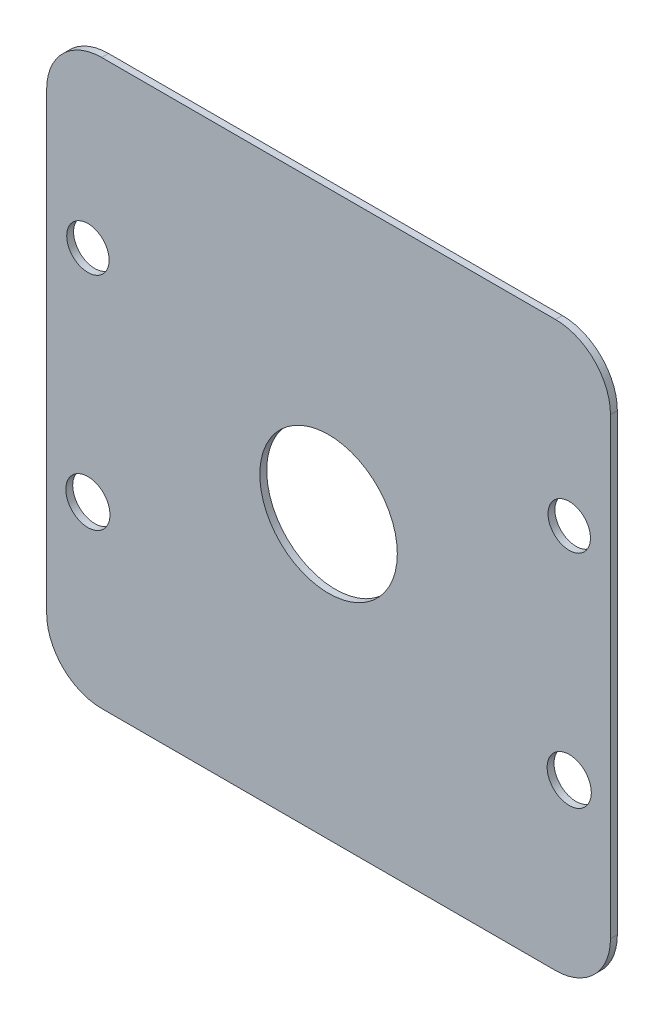
from build123d import *

# Parameters (mm, degrees)
ESBO_O1_R                = 5
ESBO_O1_R_2              = 1.606107272
ESBO_O1_R_3              = 1.541611137
RESSALTO_EXTRUS_O1_DEPTH = 0.5


with BuildPart() as part:
    # Esboço1 → Ressalto-extrusão1 (new body)
    with BuildSketch(Plane.XY):
        with BuildLine():
            Line((-16.5, -20.5), (16.5, -20.5))
            ThreePointArc((16.5, -20.5), (19.328427125, -19.328427125), (20.5, -16.5))
            Line((20.5, -16.5), (20.5, 16.5))
            ThreePointArc((20.5, 16.5), (19.328427125, 19.328427125), (16.5, 20.5))
            Line((16.5, 20.5), (-16.5, 20.5))
            ThreePointArc((-16.5, 20.5), (-19.328427125, 19.328427125), (-20.5, 16.5))
            Line((-20.5, 16.5), (-20.5, -16.5))
            ThreePointArc((-20.5, -16.5), (-19.328427125, -19.328427125), (-16.5, -20.5))
        make_face()
        Circle(ESBO_O1_R, mode=Mode.SUBTRACT)
        with Locations((17.5, -8)):
            Circle(ESBO_O1_R_2, mode=Mode.SUBTRACT)
        with Locations((17.5, 8)):
            Circle(ESBO_O1_R_3, mode=Mode.SUBTRACT)
        with Locations((-17.5, 8)):
            Circle(ESBO_O1_R_3, mode=Mode.SUBTRACT)
        with Locations((-17.5, -8)):
            Circle(ESBO_O1_R_2, mode=Mode.SUBTRACT)
    extrude(amount=RESSALTO_EXTRUS_O1_DEPTH)


solid = part.part
